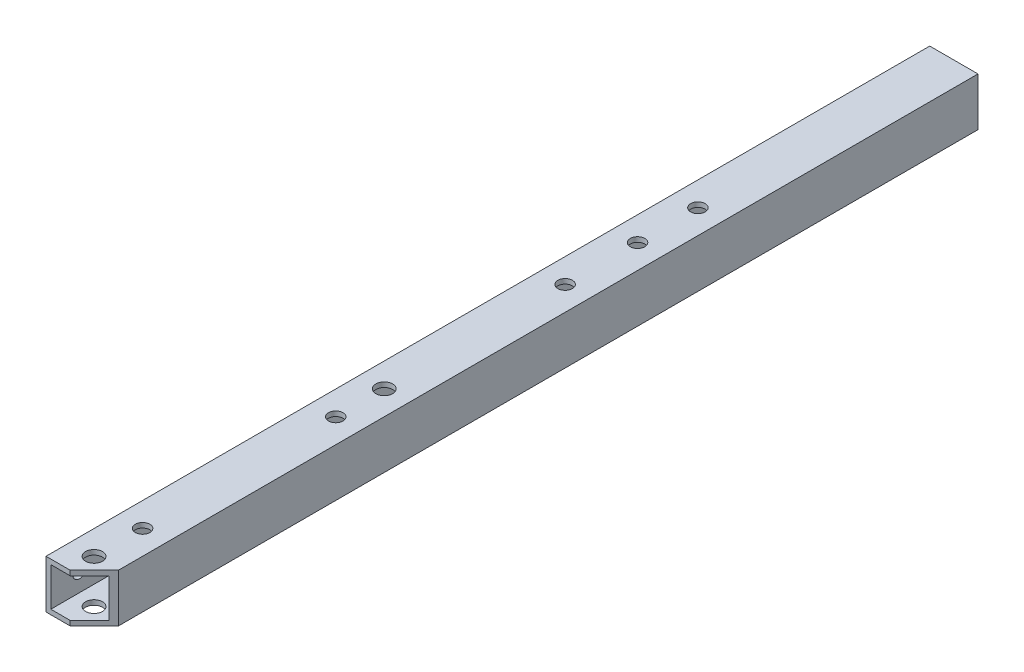
from build123d import *

# Parameters (mm, degrees)
SKETCH_1_W          = 10
SKETCH_1_H          = 10
SKETCH_1_W_2        = 8
SKETCH_1_H_2        = 8
EXTRUDE_1_DEPTH     = 183
SKETCH_2_R          = 1.75
SKETCH_2_R_2        = 1.5
CUT_EXTRUDE_1_DEPTH = 11
SKETCH_4_R          = 1.5
CUT_EXTRUDE_2_DEPTH = 5


with BuildPart() as part:
    # 草图1 → 拉伸-薄壁1 (new body)
    with BuildSketch(Plane.XY):
        Rectangle(SKETCH_1_W, SKETCH_1_H)
        Rectangle(SKETCH_1_W_2, SKETCH_1_H_2, mode=Mode.SUBTRACT)
    extrude(amount=EXTRUDE_1_DEPTH)

    # 草图2 → 切除-拉伸1 (cut, through all)
    with BuildSketch(Plane(origin=(0, 5, 0), x_dir=(1, 0, 0), z_dir=(0, 1, 0))):
        Polygon((5, -183), (5, -178), (0, -183), align=None)
        with Locations((0, -178.0520382)):
            Circle(SKETCH_2_R)
        with Locations((0, -168)):
            Circle(SKETCH_2_R_2)
        with Locations((0, -128)):
            Circle(SKETCH_2_R_2)
        with Locations((0, -117.9479618)):
            Circle(SKETCH_2_R)
        with Locations((0, -80.5)):
            Circle(SKETCH_2_R_2)
        with Locations((0, -65.5)):
            Circle(SKETCH_2_R_2)
        with Locations((0, -53)):
            Circle(SKETCH_2_R_2)
    extrude(amount=-CUT_EXTRUDE_1_DEPTH, mode=Mode.SUBTRACT)

    # 草图4 → 切除-拉伸2 (cut)
    with BuildSketch(Plane.ZY.offset(5)):
        with Locations((177, 0)):
            Circle(SKETCH_4_R)
    extrude(amount=-CUT_EXTRUDE_2_DEPTH, mode=Mode.SUBTRACT)


solid = part.part
